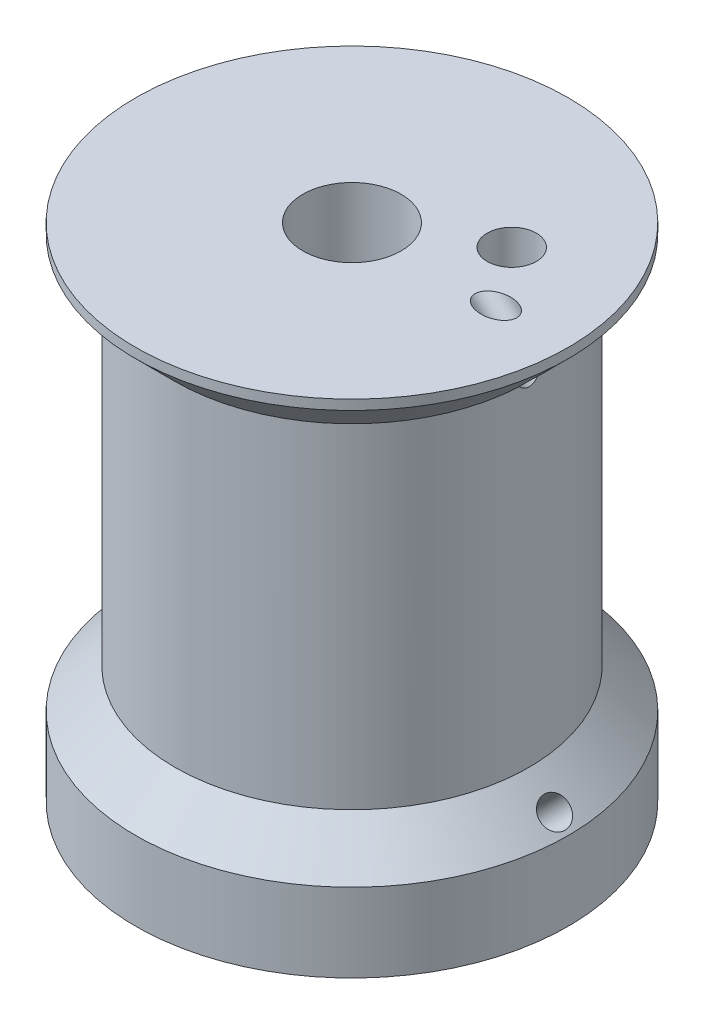
from build123d import *

# Parameters (mm, degrees)
SKETCH9_R          = 1.25
CUT_EXTRUDE2_DEPTH = 26.5
SKETCH13_W         = 1.25
SKETCH13_H         = 11


with BuildPart() as part:
    # Sketch11 → Revolve1 (revolve)
    with BuildSketch(Plane.XY):
        Polygon((2.5, 25.5), (11, 25.5), (11, 25), (9, 23), (9, 6), (11, 4), (11, 0), (2.5, 0), align=None)
    revolve(axis=Axis((0, 0, 0), (0, 1, 0)))

    # Sketch9 → Cut-Extrude2 (cut, through all)
    with BuildSketch(Plane.XZ):
        with Locations((5.152851153, -2.975)):
            Circle(SKETCH9_R)
    extrude(amount=-CUT_EXTRUDE2_DEPTH, mode=Mode.SUBTRACT)

    # Sketch10 → Cut-Revolve1 (revolve, cut)
    with BuildSketch(Plane.XY):
        Polygon((5.095658377, -0.530330086), (4.565328291, 0), (9.782664146, 5.217335854), (10.312994231, 4.687005769), align=None)
    revolve(axis=Axis((10.312994231, 4.687005769, 0), (-0.707106781, -0.707106781, 0)), mode=Mode.SUBTRACT)

    # Sketch10_3 → Cut-Revolve2 (revolve, cut)
    with BuildSketch(Plane.XY):
        Polygon((10.41573594, 22.407308798), (6.792714652, 26.030330086), (6.262384566, 25.5), (9.885405854, 21.876978712), align=None)
    revolve(axis=Axis((10.41573594, 22.407308798, 0), (-0.707106781, 0.707106781, 0)), mode=Mode.SUBTRACT)

    # Sketch13 → M3x0.5 Tapped Hole1 (revolve, cut)
    with BuildSketch(Plane(origin=(0, 2, 0), x_dir=(0, 0, -1), z_dir=(0, 1, 0))):
        with Locations((0.625, 5.5)):
            Rectangle(SKETCH13_W, SKETCH13_H)
    revolve(axis=Axis((6.35, 2, 0), (-1, 0, 0)), mode=Mode.SUBTRACT)


solid = part.part
